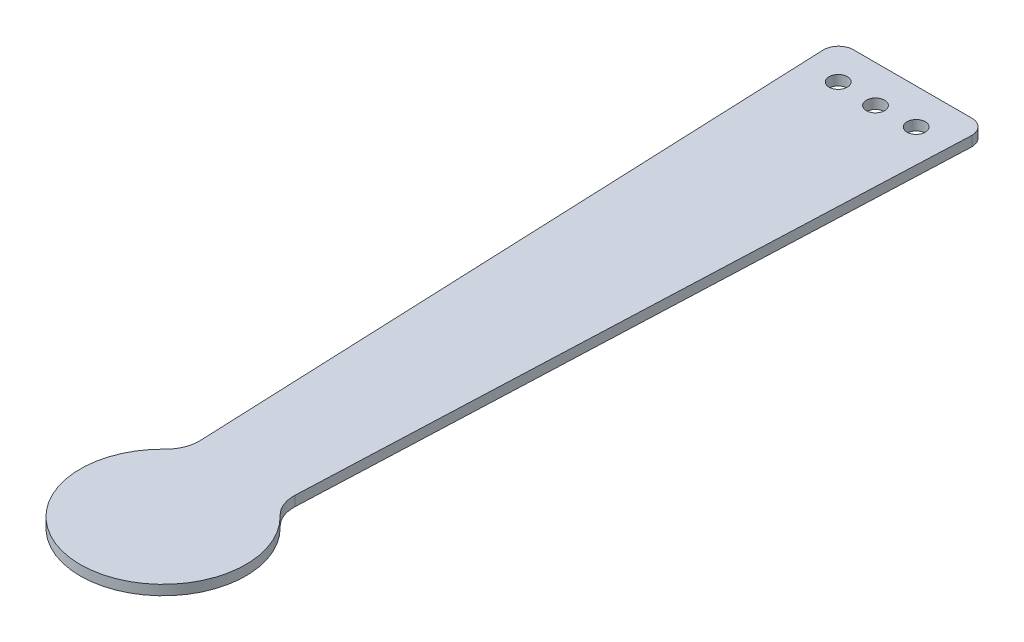
from build123d import *

# Parameters (mm, degrees)
SKETCH1_R           = 2.75
SKETCH1_R_2         = 15
SKETCH1_R_3         = 5
BOSS_EXTRUDE3_DEPTH = 3


with BuildPart() as part:
    # Sketch1 → Boss-Extrude3 (new body)
    with BuildSketch(Plane(origin=(0, 0, 0), x_dir=(1, 0, 0), z_dir=(0, 1, 0))):
        with BuildLine():
            Line((-17.506658739, 0), (-18.165165803, 0))
            ThreePointArc((-18.165165803, 0), (-21.149463035, -1.424316358), (-22.376192782, -4.495121005))
            Line((-22.376192782, -4.495121005), (-14.295317192, -200.74104694))
            ThreePointArc((-14.295317192, -200.74104694), (-15.017989675, -204.775435104), (-17.298404685, -208.181055571))
            ThreePointArc((-17.298404685, -208.181055571), (0, -201.226886238), (17.298404685, -208.181055571))
            ThreePointArc((17.298404685, -208.181055571), (15.017989675, -204.775435104), (14.295317192, -200.74104694))
            Line((14.295317192, -200.74104694), (22.376192782, -4.495121005))
            ThreePointArc((22.376192782, -4.495121005), (21.149463035, -1.424316358), (18.165165803, 0))
            Line((18.165165803, 0), (17.506658739, 0))
            Line((17.506658739, 0), (-17.506658739, 0))
        make_face()
        with Locations((-11.757886925, -10.70503214)):
            Circle(SKETCH1_R, mode=Mode.SUBTRACT)
        with Locations((0.008138346, -11.218747897)):
            Circle(SKETCH1_R, mode=Mode.SUBTRACT)
        with Locations((11.774163618, -10.70503214)):
            Circle(SKETCH1_R, mode=Mode.SUBTRACT)
        with BuildLine():
            ThreePointArc((17.298404685, -208.181055571), (0, -201.226886238), (-17.298404685, -208.181055571))
            ThreePointArc((-17.298404685, -208.181055571), (-17.349081254, -208.230277568), (-17.400104292, -208.279140328))
            ThreePointArc((-17.400104292, -208.279140328), (-9.739921707, -249.234548423), (24.991861654, -226.218747892))
            ThreePointArc((24.991861654, -226.218747892), (23.015800531, -216.478826185), (17.400104292, -208.279140328))
            ThreePointArc((17.400104292, -208.279140328), (17.349081254, -208.230277568), (17.298404685, -208.181055571))
        make_face()
        with Locations((0, -226.218747892)):
            Circle(SKETCH1_R_2, mode=Mode.SUBTRACT)
        with Locations((0, -226.218747892)):
            Circle(SKETCH1_R_2)
        with Locations((0, -226.218747892)):
            Circle(SKETCH1_R_3, mode=Mode.SUBTRACT)
        with Locations((0, -226.218747892)):
            Circle(SKETCH1_R_3)
    extrude(amount=BOSS_EXTRUDE3_DEPTH)


solid = part.part
